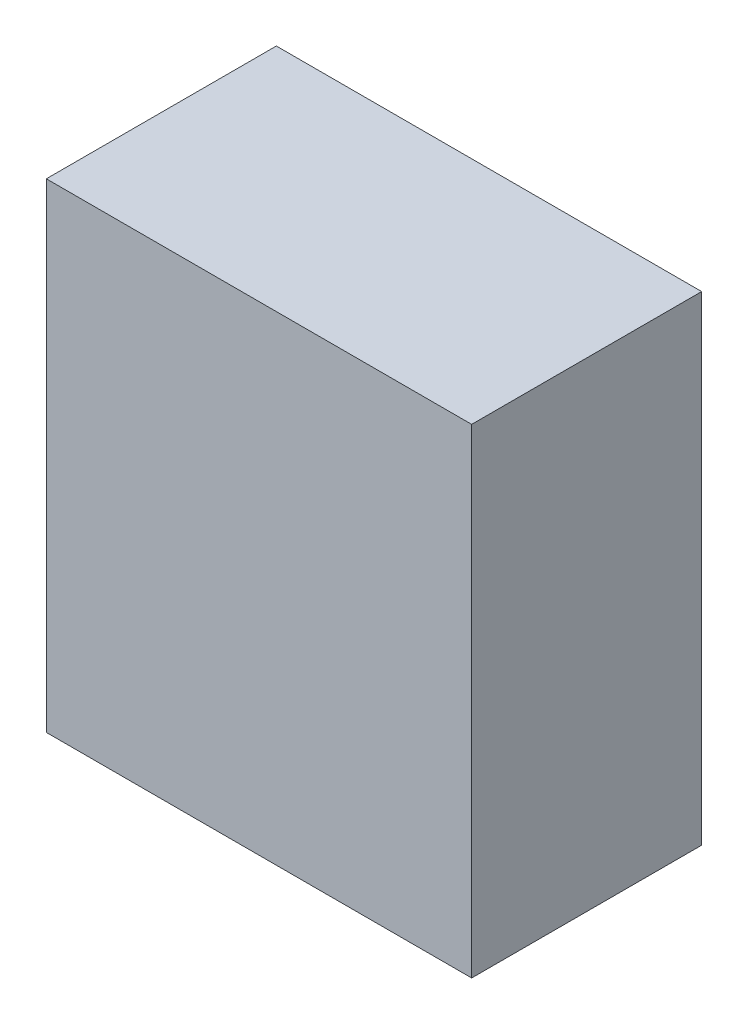
from build123d import *

# Parameters (mm, degrees)
BOSS_EXTRUDE1_DEPTH = 12.35
SKETCH2_W           = 28.386130872
SKETCH2_H           = 32
BOSS_EXTRUDE2_DEPTH = 3


with BuildPart() as part:
    # Sketch1 → Boss-Extrude1 (new body)
    with BuildSketch(Plane.XY):
        Polygon((-155.366706922, 7.584180911), (-172.666706922, 7.584180911), (-172.666706922, 12.334180911), (-144.28057605, 12.334180911), (-144.28057605, -19.665819089), (-172.666706922, -19.665819089), (-172.666706922, -14.915819089), (-155.366706922, -14.915819089), align=None)
    extrude(amount=-BOSS_EXTRUDE1_DEPTH)

    # Sketch2 → Boss-Extrude2 (add)
    with BuildSketch(Plane.XY):
        with Locations((-158.473641486, -3.665819089)):
            Rectangle(SKETCH2_W, SKETCH2_H)
    extrude(amount=BOSS_EXTRUDE2_DEPTH)


solid = part.part
